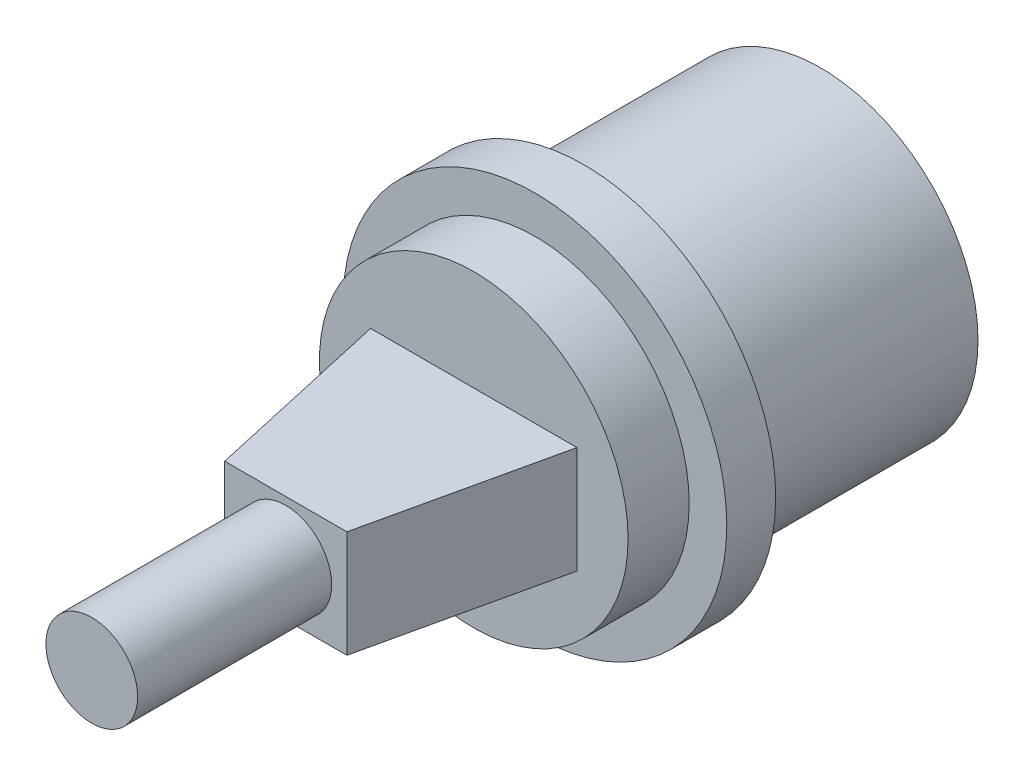
from build123d import *

# Parameters (mm, degrees)
BOSS_EXTRUDE1_DEPTH = 3.5
SKETCH3_W           = 13.5
SKETCH3_H           = 6
CUT_EXTRUDE1_DEPTH  = 10
CUT_EXTRUDE2_DEPTH  = 15.5


with BuildPart() as part:
    # Sketch1 → Revolve1 (revolve)
    with BuildSketch(Plane(origin=(0, 0, 0), x_dir=(0, 0, -1), z_dir=(1, 0, 0))):
        Polygon((-32.2, 0), (15.5, 0), (15.5, 10.3), (0, 10.3), (0, 12.56), (-3.2, 12.56), (-3.2, 10.1), (-7.2, 10.1), (-7.2, 3), (-32.2, 3), align=None)
    revolve(axis=Axis((0, 0, -15.5), (0, 0, -1)))

    # Sketch2 → Boss-Extrude1 (add, symmetric)
    with BuildSketch(Plane(origin=(0, 0, 0), x_dir=(1, 0, 0), z_dir=(0, 1, 0))):
        Polygon((-6.75, -7.2), (6.75, -7.2), (4, -19.5), (-4, -19.5), align=None)
    extrude(amount=BOSS_EXTRUDE1_DEPTH, both=True)

    # Sketch3 → Cut-Extrude1 (cut)
    with BuildSketch(Plane(origin=(0, 0, -15.5), x_dir=(-1, 0, 0), z_dir=(0, 0, -1))):
        Rectangle(SKETCH3_W, SKETCH3_H)
    extrude(amount=-CUT_EXTRUDE1_DEPTH, mode=Mode.SUBTRACT)

    # Sketch4 → Cut-Extrude2 (cut)
    with BuildSketch(Plane(origin=(0, 0, -15.5), x_dir=(-1, 0, 0), z_dir=(0, 0, -1))):
        with BuildLine():
            Line((8.6, 5.668333088), (8.6, -5.668333088))
            ThreePointArc((8.6, -5.668333088), (10.3, 0), (8.6, 5.668333088))
        make_face()
    extrude(amount=-CUT_EXTRUDE2_DEPTH, mode=Mode.SUBTRACT)


solid = part.part
